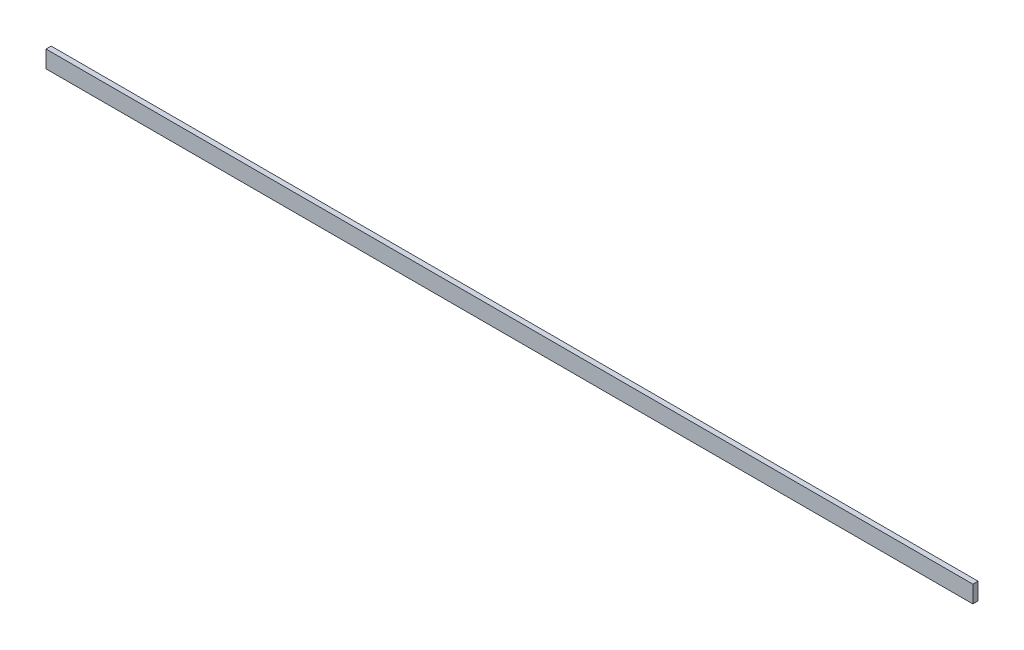
from build123d import *

# Parameters (mm, degrees)
SKETCH1_W           = 540
SKETCH1_H           = 10
BOSS_EXTRUDE1_DEPTH = 3


with BuildPart() as part:
    # Sketch1 → Boss-Extrude1 (new body)
    with BuildSketch(Plane.XY):
        Rectangle(SKETCH1_W, SKETCH1_H)
    extrude(amount=BOSS_EXTRUDE1_DEPTH)


solid = part.part
